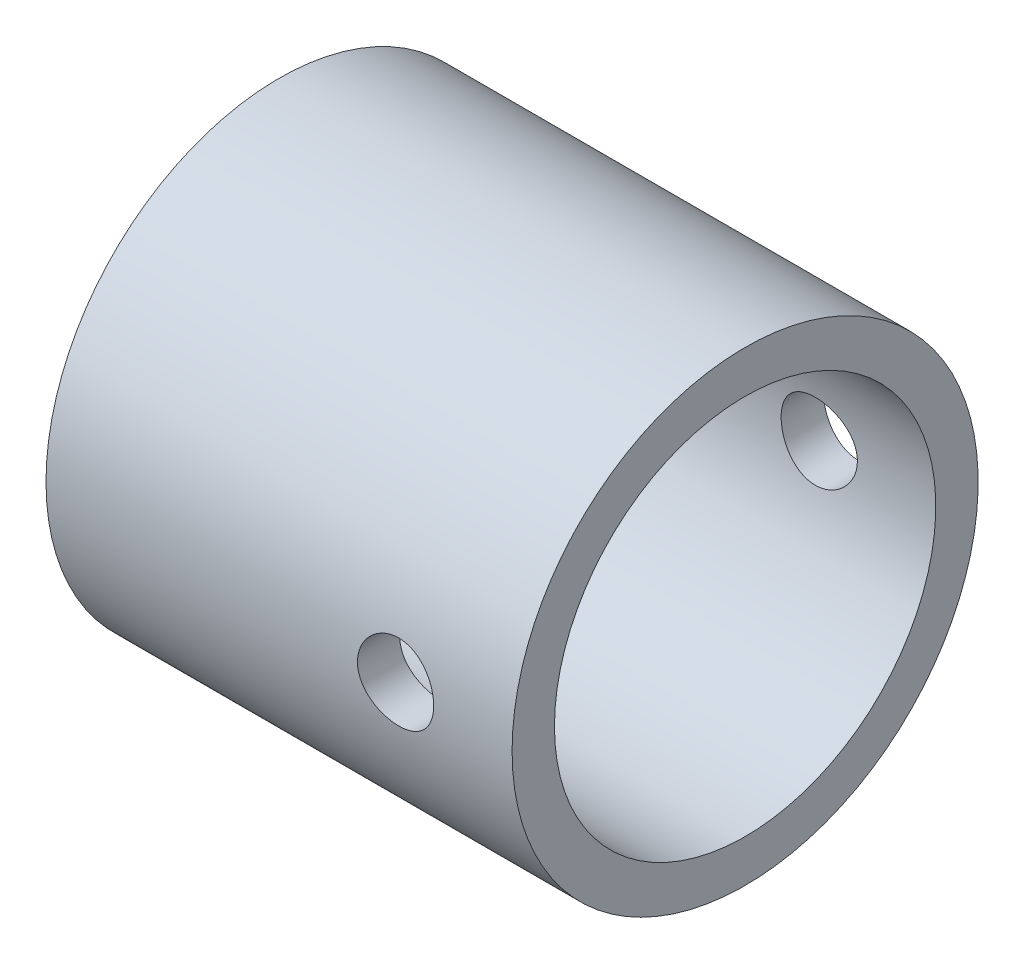
from build123d import *

# Parameters (mm, degrees)
SKETCH5_R               = 0.9
CUT_EXTRUDE2_DEPTH      = 6.5
CUT_EXTRUDE2_DEPTH_BACK = 6.5


with BuildPart() as part:
    # Sketch3 → Revolve19 (revolve)
    with BuildSketch(Plane.XY):
        Polygon((262.558388758, -144.573704322), (262.558388758, -144.073704322), (272.558388758, -144.073704322), (272.558388758, -143.073704322), (261.558388758, -143.073704322), (261.558388758, -144.323704322), (261.558388758, -148.073704322), (263.058388758, -148.073704322), (263.058388758, -144.573704322), align=None)
    revolve(axis=Axis((263.058388758, -148.573704322, 0), (1, 0, 0)))

    # Sketch5 → Cut-Extrude2 (cut, two sides)
    with BuildSketch(Plane.XY) as cut_extrude2_sk:
        with Locations((269.808388758, -148.573704322)):
            Circle(SKETCH5_R)
    extrude(amount=CUT_EXTRUDE2_DEPTH, mode=Mode.SUBTRACT)
    extrude(cut_extrude2_sk.sketch, amount=-CUT_EXTRUDE2_DEPTH_BACK, mode=Mode.SUBTRACT)


solid = part.part
